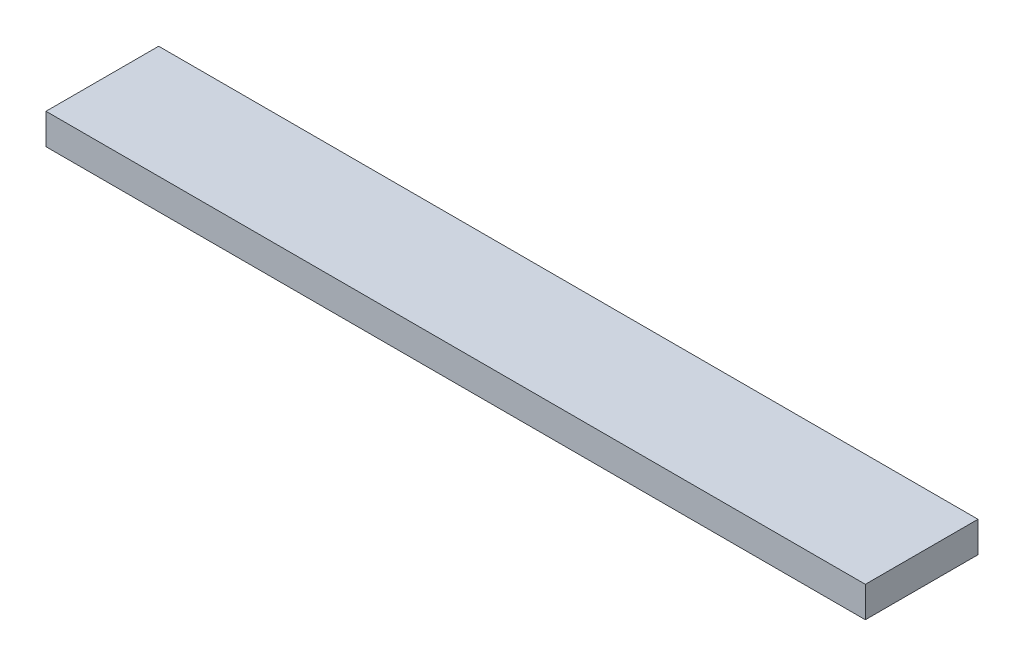
from build123d import *

# Parameters (mm, degrees)
SKETCH1_W           = 508
SKETCH1_H           = 69.85
BOSS_EXTRUDE1_DEPTH = 19.05


with BuildPart() as part:
    # Sketch1 → Boss-Extrude1 (new body)
    with BuildSketch(Plane(origin=(0, 0, 0), x_dir=(1, 0, 0), z_dir=(0, 1, 0))):
        with Locations((254, 34.925)):
            Rectangle(SKETCH1_W, SKETCH1_H)
    extrude(amount=BOSS_EXTRUDE1_DEPTH)


solid = part.part
